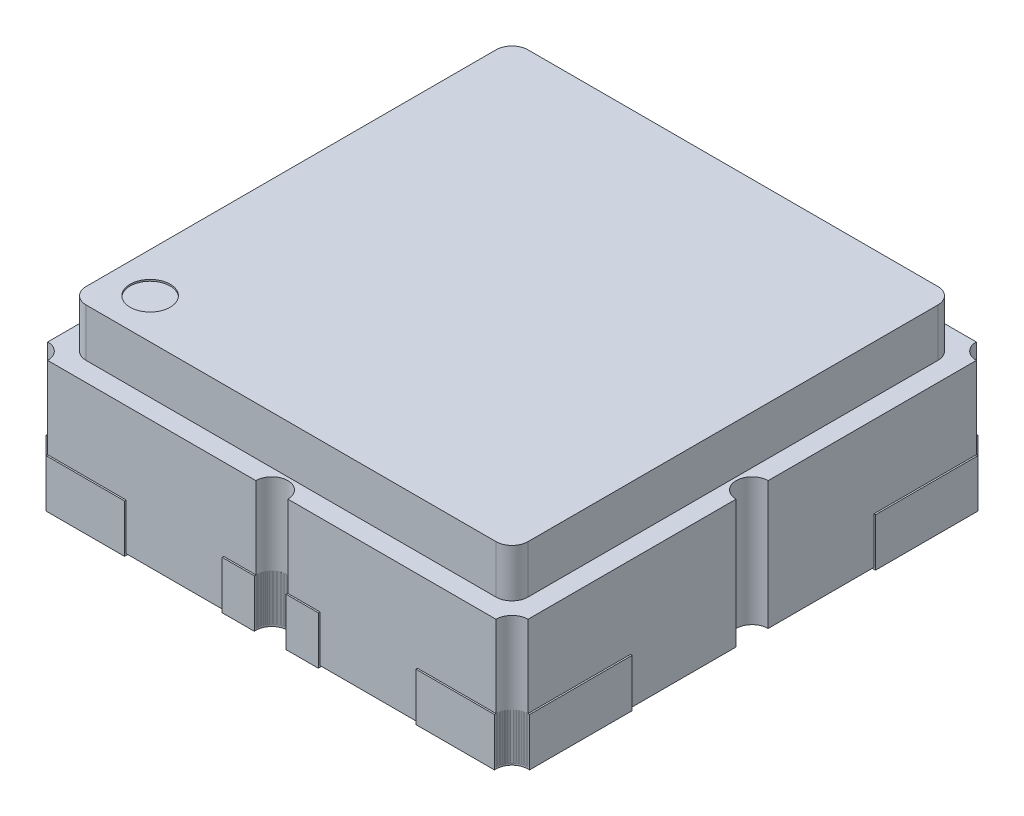
from build123d import *

# Parameters (mm, degrees)
SKETCH2_W             = 3
SKETCH2_H             = 3
BOSS_EXTRUDE1_DEPTH   = 0.8
BOSS_EXTRUDE2_DEPTH   = 0.3
BOSS_EXTRUDE3_START   = 0.01
SKETCH5_W             = 0.6
SKETCH5_H             = 0.75
BOSS_EXTRUDE3_DEPTH   = 0.3
SKETCH5_H_2           = 1.5
BOSS_EXTRUDE3_2_DEPTH = 0.3
BOSS_EXTRUDE3_3_DEPTH = 0.3
BOSS_EXTRUDE3_4_DEPTH = 0.3
BOSS_EXTRUDE3_5_DEPTH = 0.3
BOSS_EXTRUDE3_6_DEPTH = 0.3
SKETCH3_R             = 0.1
CUT_EXTRUDE1_DEPTH    = 1.81
SKETCH6_R             = 0.125
CUT_EXTRUDE2_DEPTH    = 0.01


with BuildPart() as part:
    # Sketch2 → Boss-Extrude1 (new body)
    with BuildSketch(Plane(origin=(0, 0, 0), x_dir=(1, 0, 0), z_dir=(0, 1, 0))):
        Rectangle(SKETCH2_W, SKETCH2_H)
    extrude(amount=BOSS_EXTRUDE1_DEPTH)

    # Sketch4 → Boss-Extrude2 (add)
    with BuildSketch(Plane(origin=(0, 0.8, 0), x_dir=(1, 0, 0), z_dir=(0, 1, 0))):
        with BuildLine():
            Line((-1.28, -1.38), (1.28, -1.38))
            ThreePointArc((1.28, -1.38), (1.350710678, -1.350710678), (1.38, -1.28))
            Line((1.38, -1.28), (1.38, 1.28))
            ThreePointArc((1.38, 1.28), (1.350710678, 1.350710678), (1.28, 1.38))
            Line((1.28, 1.38), (-1.28, 1.38))
            ThreePointArc((-1.28, 1.38), (-1.350710678, 1.350710678), (-1.38, 1.28))
            Line((-1.38, 1.28), (-1.38, -1.28))
            ThreePointArc((-1.38, -1.28), (-1.350710678, -1.350710678), (-1.28, -1.38))
        make_face()
    extrude(amount=BOSS_EXTRUDE2_DEPTH)


with BuildPart() as body_2:
    # Sketch5 → Boss-Extrude3 (new body)
    with BuildSketch(Plane.XZ.offset(BOSS_EXTRUDE3_START)):
        with Locations((-1.21, -1.135)):
            Rectangle(SKETCH5_W, SKETCH5_H)
    extrude(amount=-BOSS_EXTRUDE3_DEPTH)


with BuildPart() as body_3:
    # Sketch5 → Boss-Extrude3 2 (new body)
    with BuildSketch(Plane.XZ.offset(BOSS_EXTRUDE3_START)):
        with Locations((-1.21, 0.76)):
            Rectangle(SKETCH5_W, SKETCH5_H_2)
    extrude(amount=-BOSS_EXTRUDE3_2_DEPTH)


with BuildPart() as body_4:
    # Sketch5 → Boss-Extrude3 3 (new body)
    with BuildSketch(Plane.XZ.offset(BOSS_EXTRUDE3_START)):
        with Locations((0, -1.135)):
            Rectangle(SKETCH5_W, SKETCH5_H)
    extrude(amount=-BOSS_EXTRUDE3_3_DEPTH)


with BuildPart() as body_5:
    # Sketch5 → Boss-Extrude3 4 (new body)
    with BuildSketch(Plane.XZ.offset(BOSS_EXTRUDE3_START)):
        with Locations((1.21, -1.135)):
            Rectangle(SKETCH5_W, SKETCH5_H)
    extrude(amount=-BOSS_EXTRUDE3_4_DEPTH)


with BuildPart() as body_6:
    # Sketch5 → Boss-Extrude3 5 (new body)
    with BuildSketch(Plane.XZ.offset(BOSS_EXTRUDE3_START)):
        with Locations((1.21, 1.135)):
            Rectangle(SKETCH5_W, SKETCH5_H)
    extrude(amount=-BOSS_EXTRUDE3_5_DEPTH)


with BuildPart() as body_7:
    # Sketch5 → Boss-Extrude3 6 (new body)
    with BuildSketch(Plane.XZ.offset(BOSS_EXTRUDE3_START)):
        with Locations((0, 1.135)):
            Rectangle(SKETCH5_W, SKETCH5_H)
    extrude(amount=-BOSS_EXTRUDE3_6_DEPTH)


with BuildPart() as cut_extrude1_tool:
    # Sketch3 → Cut-Extrude1 (new body, through all)
    with BuildSketch(Plane(origin=(0, 0.8, 0), x_dir=(1, 0, 0), z_dir=(0, 1, 0))):
        with Locations((-1.5, 1.5)):
            Circle(SKETCH3_R)
        with Locations((0, 1.5)):
            Circle(SKETCH3_R)
        with Locations((1.5, 1.5)):
            Circle(SKETCH3_R)
        with Locations((-1.5, 0)):
            Circle(SKETCH3_R)
        with Locations((1.5, 0)):
            Circle(SKETCH3_R)
        with Locations((1.5, -1.5)):
            Circle(SKETCH3_R)
        with Locations((0, -1.5)):
            Circle(SKETCH3_R)
        with Locations((-1.5, -1.5)):
            Circle(SKETCH3_R)
    extrude(amount=-CUT_EXTRUDE1_DEPTH)


with BuildPart() as part_1:
    add(part.part)

    # Cut-Extrude1: cut by cut_extrude1_tool
    add(cut_extrude1_tool.part, mode=Mode.SUBTRACT)

    # Sketch6 → Cut-Extrude2 (cut)
    with BuildSketch(Plane(origin=(0, 1.1, 0), x_dir=(1, 0, 0), z_dir=(0, 1, 0))):
        with Locations((-1.13, -1.13)):
            Circle(SKETCH6_R)
    extrude(amount=-CUT_EXTRUDE2_DEPTH, mode=Mode.SUBTRACT)


with BuildPart() as body_2_1:
    add(body_2.part)

    # Cut-Extrude1: cut by cut_extrude1_tool
    add(cut_extrude1_tool.part, mode=Mode.SUBTRACT)


with BuildPart() as body_3_1:
    add(body_3.part)

    # Cut-Extrude1: cut by cut_extrude1_tool
    add(cut_extrude1_tool.part, mode=Mode.SUBTRACT)


with BuildPart() as body_4_1:
    add(body_4.part)

    # Cut-Extrude1: cut by cut_extrude1_tool
    add(cut_extrude1_tool.part, mode=Mode.SUBTRACT)


with BuildPart() as body_5_1:
    add(body_5.part)

    # Cut-Extrude1: cut by cut_extrude1_tool
    add(cut_extrude1_tool.part, mode=Mode.SUBTRACT)


with BuildPart() as body_6_1:
    add(body_6.part)

    # Cut-Extrude1: cut by cut_extrude1_tool
    add(cut_extrude1_tool.part, mode=Mode.SUBTRACT)


with BuildPart() as body_7_1:
    add(body_7.part)

    # Cut-Extrude1: cut by cut_extrude1_tool
    add(cut_extrude1_tool.part, mode=Mode.SUBTRACT)


solid = Compound([part_1.part, body_2_1.part, body_3_1.part, body_4_1.part, body_5_1.part, body_6_1.part, body_7_1.part])
